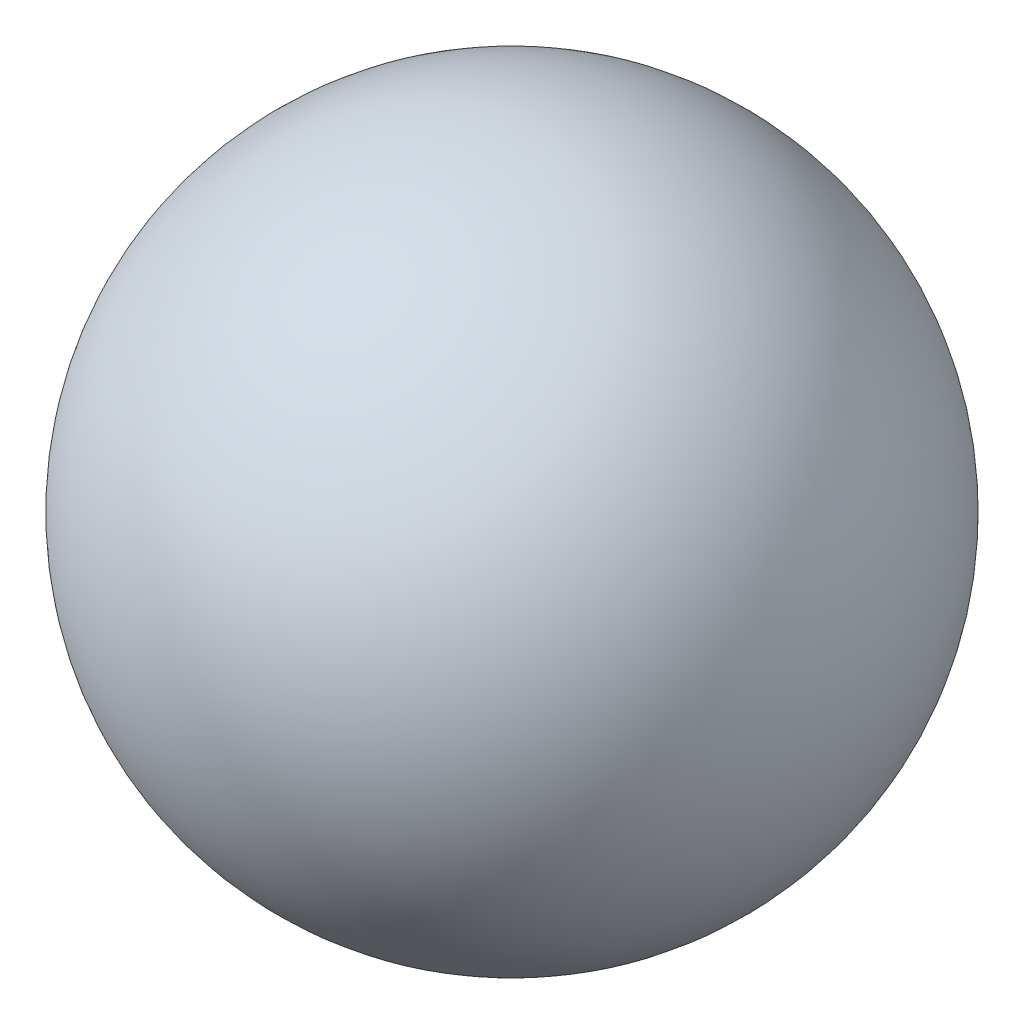
from build123d import *


with BuildPart() as part:
    # Esquisse1 → R_volution1 (revolve)
    with BuildSketch(Plane.XY):
        with BuildLine():
            Line((0, 20.5), (0, 16.5))
            ThreePointArc((0, 16.5), (-2, 18.5), (0, 20.5))
        make_face()
    revolve(axis=Axis((0, 0, 0), (0, 1, 0)))


solid = part.part
